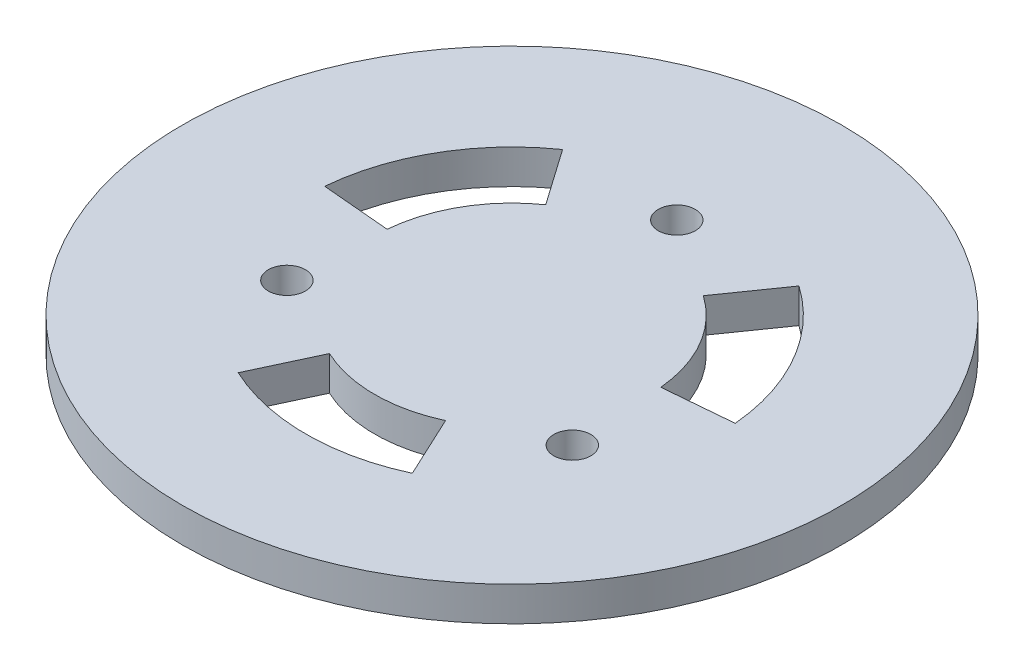
from build123d import *

# Parameters (mm, degrees)
SKETCH1_R           = 23.99268
SKETCH1_R_2         = 1.35
BOSS_EXTRUDE1_DEPTH = 2.5
CUT_EXTRUDE2_DEPTH  = 10


with BuildPart() as part:
    # Sketch1 → Boss-Extrude1 (new body)
    with BuildSketch(Plane(origin=(0, 0, 0), x_dir=(1, 0, 0), z_dir=(0, 1, 0))):
        Circle(SKETCH1_R)
        with Locations((0, 11.99634)):
            Circle(SKETCH1_R_2, mode=Mode.SUBTRACT)
        with Locations((10.389135192, -5.99817)):
            Circle(SKETCH1_R_2, mode=Mode.SUBTRACT)
        with Locations((-10.389135192, -5.99817)):
            Circle(SKETCH1_R_2, mode=Mode.SUBTRACT)
    extrude(amount=BOSS_EXTRUDE1_DEPTH)

    # Sketch3 → Cut-Extrude2 (cut)
    with BuildSketch(Plane(origin=(0, 2.5, 0), x_dir=(1, 0, 0), z_dir=(0, 1, 0))):
        with BuildLine():
            Line((5.735764364, 8.191520443), (8.603646545, 12.287280664))
            ThreePointArc((8.603646545, 12.287280664), (12.990381057, 7.5), (14.942920471, 1.307336141))
            Line((14.942920471, 1.307336141), (9.961946981, 0.871557427))
            ThreePointArc((9.961946981, 0.871557427), (8.660254038, 5), (5.735764364, 8.191520443))
        make_face()
        with BuildLine():
            Line((4.226182617, -9.06307787), (6.339273926, -13.594616806))
            ThreePointArc((6.339273926, -13.594616806), (0, -15), (-6.339273926, -13.594616806))
            Line((-6.339273926, -13.594616806), (-4.226182617, -9.06307787))
            ThreePointArc((-4.226182617, -9.06307787), (0, -10), (4.226182617, -9.06307787))
        make_face()
        with BuildLine():
            Line((-9.961946981, 0.871557427), (-14.942920471, 1.307336141))
            ThreePointArc((-14.942920471, 1.307336141), (-12.990381057, 7.5), (-8.603646545, 12.287280664))
            Line((-8.603646545, 12.287280664), (-5.735764364, 8.191520443))
            ThreePointArc((-5.735764364, 8.191520443), (-8.660254038, 5), (-9.961946981, 0.871557427))
        make_face()
    extrude(amount=-CUT_EXTRUDE2_DEPTH, mode=Mode.SUBTRACT)


solid = part.part
